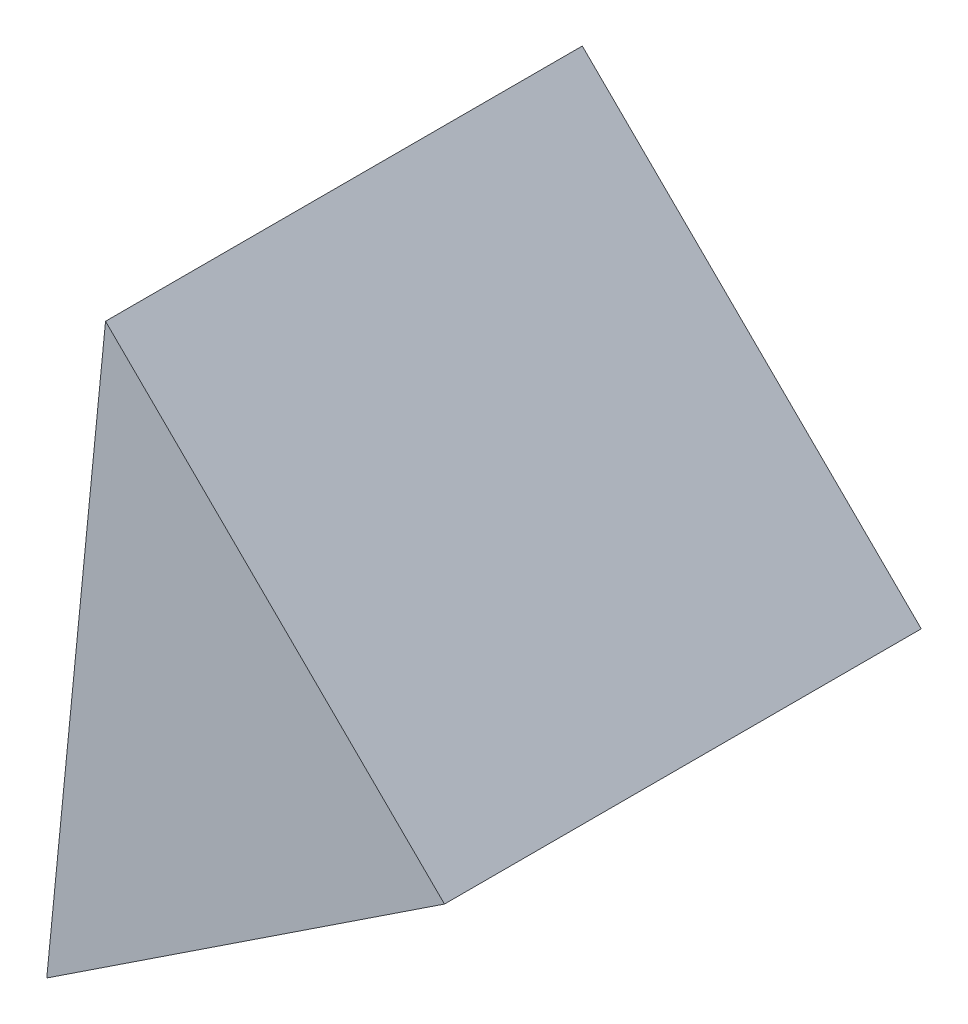
from build123d import *

# Parameters (mm, degrees)
EXTRUDE_1_DEPTH = 10


with BuildPart() as part:
    # 草图2 → 凸台-拉伸1 (new body)
    with BuildSketch(Plane.XY):
        Polygon((9.028570852, 6.361486365), (1.918842616, 13.393681215), (0.686170974, 0.847471105), align=None)
    extrude(amount=EXTRUDE_1_DEPTH)


solid = part.part
